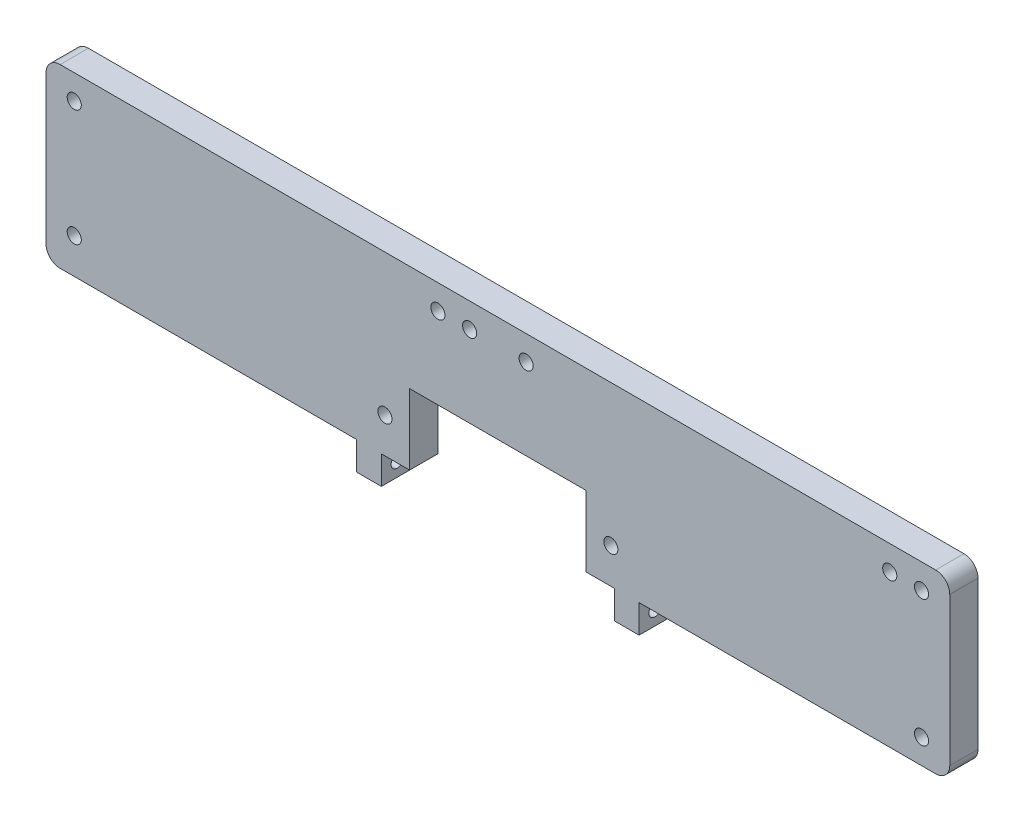
from build123d import *

# Parameters (mm, degrees)
SKETCH1_W           = 256
SKETCH1_H           = 50
SKETCH1_R           = 2
BOSS_EXTRUDE1_DEPTH = 8
FILLET1_R           = 4
SKETCH2_W           = 7
SKETCH2_H           = 8
BOSS_EXTRUDE2_DEPTH = 8
SKETCH3_W           = 50
SKETCH3_H           = 20
CUT_EXTRUDE1_DEPTH  = 8
SKETCH4_R           = 2
CUT_EXTRUDE2_DEPTH  = 8
SKETCH5_R           = 1.75
CUT_EXTRUDE3_DEPTH  = 113


with BuildPart() as part:
    # Sketch1 → Boss-Extrude1 (new body)
    with BuildSketch(Plane.XY):
        with Locations((0.283809042, 47.106089777)):
            Rectangle(SKETCH1_W, SKETCH1_H)
        with Locations((120.283809042, 65.106089777)):
            Circle(SKETCH1_R, mode=Mode.SUBTRACT)
        with Locations((111.283809042, 65.106089777)):
            Circle(SKETCH1_R, mode=Mode.SUBTRACT)
        with Locations((8.283809042, 65.106089777)):
            Circle(SKETCH1_R, mode=Mode.SUBTRACT)
        with Locations((-7.716190958, 65.106089777)):
            Circle(SKETCH1_R, mode=Mode.SUBTRACT)
        with Locations((-16.716190958, 65.106089777)):
            Circle(SKETCH1_R, mode=Mode.SUBTRACT)
        with Locations((-119.716190958, 65.106089777)):
            Circle(SKETCH1_R, mode=Mode.SUBTRACT)
    extrude(amount=BOSS_EXTRUDE1_DEPTH)

    # Fillet1
    fillet1_edges = [part.edges().sort_by_distance(p)[0] for p in [
        (-127.716190958, 72.106089777, 4),
        (128.283809042, 72.106089777, 4),
        (128.283809042, 22.106089777, 4),
        (-127.716190958, 22.106089777, 4),
    ]]
    fillet(fillet1_edges, radius=FILLET1_R)

    # Sketch2 → Boss-Extrude2 (add)
    with BuildSketch(Plane.XY.offset(8)):
        with Locations((36.783809042, 18.106089777)):
            Rectangle(SKETCH2_W, SKETCH2_H)
        with Locations((-36.216190958, 18.106089777)):
            Rectangle(SKETCH2_W, SKETCH2_H)
    extrude(amount=-BOSS_EXTRUDE2_DEPTH)

    # Sketch3 → Cut-Extrude1 (cut)
    with BuildSketch(Plane.XY.offset(8)):
        with Locations((0.283809042, 32.106089777)):
            Rectangle(SKETCH3_W, SKETCH3_H)
    extrude(amount=-CUT_EXTRUDE1_DEPTH, mode=Mode.SUBTRACT)

    # Sketch4 → Cut-Extrude2 (cut)
    with BuildSketch(Plane.XY.offset(8)):
        with Locations((-31.716190958, 32.106089777)):
            Circle(SKETCH4_R)
        with Locations((32.283809042, 32.106089777)):
            Circle(SKETCH4_R)
        with Locations((-119.716190958, 32.106089777)):
            Circle(SKETCH4_R)
        with Locations((120.283809042, 29.106089777)):
            Circle(SKETCH4_R)
    extrude(amount=-CUT_EXTRUDE2_DEPTH, mode=Mode.SUBTRACT)

    # Sketch5 → Cut-Extrude3 (cut)
    with BuildSketch(Plane.ZY.offset(39.716190958)):
        with Locations((3.5, 18.106089777)):
            Circle(SKETCH5_R)
    extrude(amount=-CUT_EXTRUDE3_DEPTH, mode=Mode.SUBTRACT)


solid = part.part
